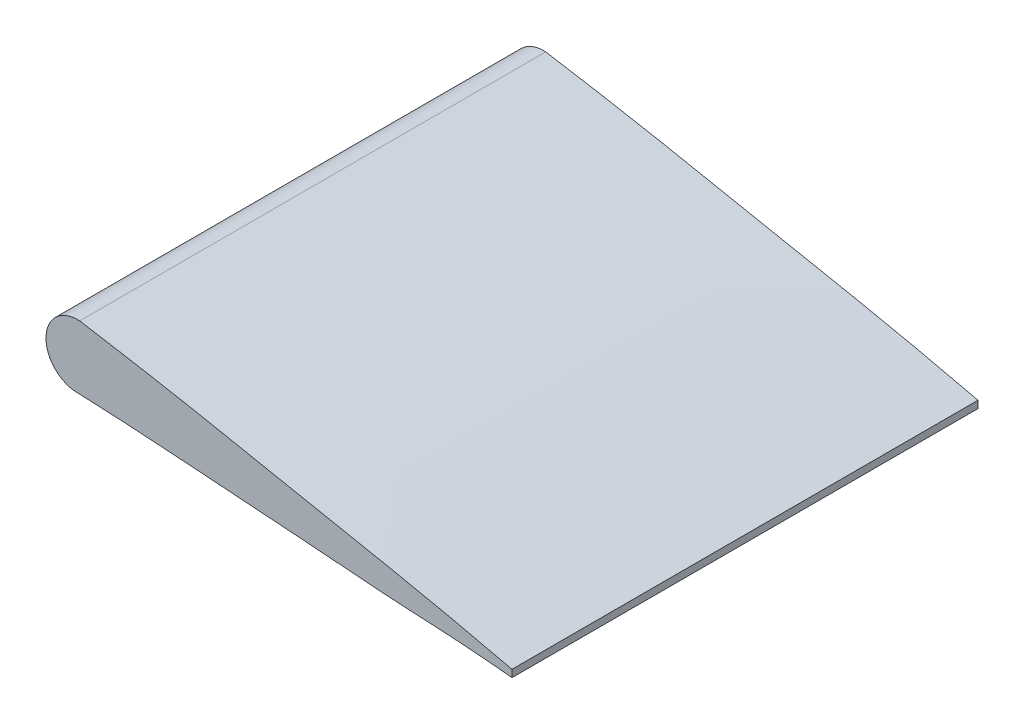
from build123d import *

# Parameters (mm, degrees)
BOSS_EXTRUDE1_DEPTH = 114.3


with BuildPart() as part:
    # Sketch1 → Boss-Extrude1 (new body)
    with BuildSketch(Plane.XY):
        with BuildLine():
            Line((254, -0.889), (254, 0.889))
            add(Edge.make_bspline(
                [(254, 0.889), (249.755300971, 1.878593359), (241.284220881, 3.853509493), (224.315824879, 7.473607963), (203.056452147, 11.527247876), (177.661285298, 16.728315171), (159.271445788, 20.022431729), (149.372045682, 21.653055355), (147.97786, 21.878845413)],
                knots=[0, 0, 0, 0, 0.025044993, 0.049981904, 0.099692877, 0.149404795, 0.198930977, 0.207045259, 0.207045259, 0.207045259, 0.207045259], degree=3))
            ThreePointArc((147.97786, 21.878845413), (142.156665485, 19.779994096), (139.7, 14.100533107))
            ThreePointArc((139.7, 14.100533107), (141.60956807, 8.989999859), (146.402491493, 6.383875276))
            add(Edge.make_bspline(
                [(146.402491493, 6.383875276), (146.927641819, 6.363923621), (147.452765169, 6.343386084), (147.97786, 6.3222208)],
                knots=[0.793421305, 0.793421305, 0.793421305, 0.793421305, 0.796441456, 0.796441456, 0.796441456, 0.796441456], degree=3))
            add(Edge.make_bspline(
                [(147.97786, 6.3222208), (149.428428511, 6.263751943), (159.359633347, 5.830586303), (177.755025487, 4.534004477), (203.173260157, 2.785083613), (224.33530321, 1.016787469), (241.313406146, 0.326551109), (249.768531374, -0.483566797), (254, -0.889)],
                knots=[0.796441456, 0.796441456, 0.796441456, 0.796441456, 0.804784589, 0.853570641, 0.902385984, 0.951201328, 0.97557812, 1, 1, 1, 1], degree=3))
        make_face()
    extrude(amount=BOSS_EXTRUDE1_DEPTH)


solid = part.part
